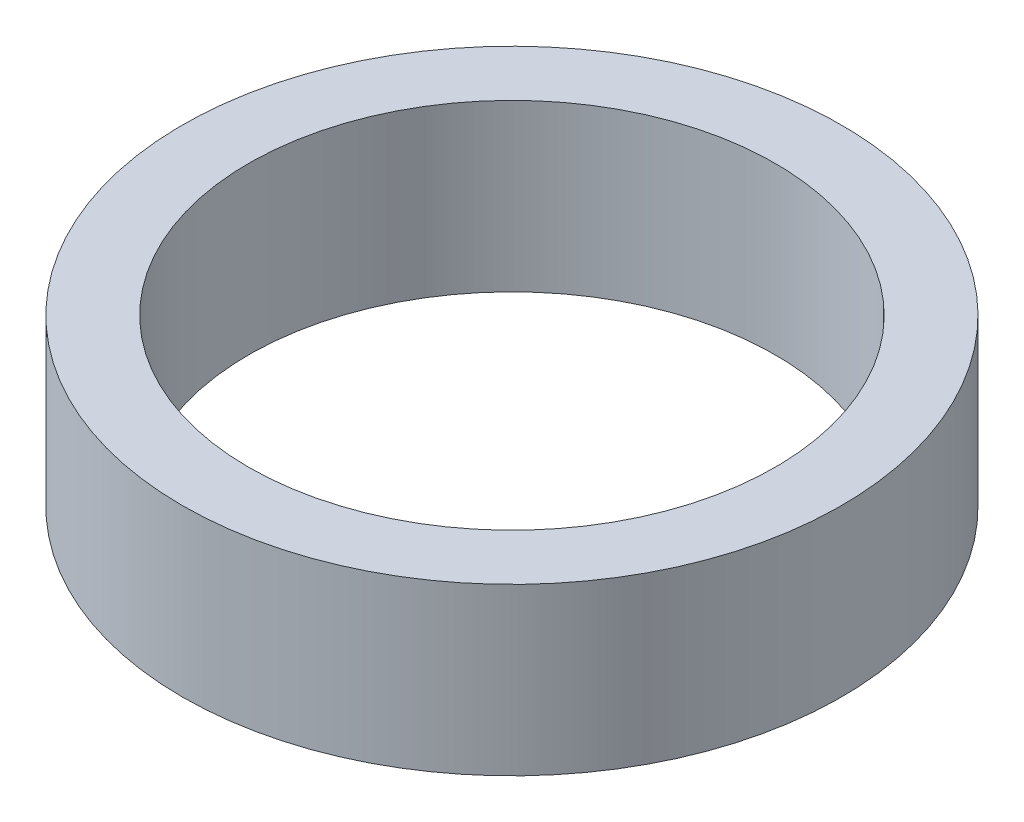
from build123d import *

# Parameters (mm, degrees)
SKETCH1_R           = 15.775
SKETCH1_R_2         = 12.6
BOSS_EXTRUDE1_DEPTH = 3.96875


with BuildPart() as part:
    # Sketch1 → Boss-Extrude1 (new body, symmetric)
    with BuildSketch(Plane(origin=(0, 0, 0), x_dir=(1, 0, 0), z_dir=(0, 1, 0))):
        Circle(SKETCH1_R)
        Circle(SKETCH1_R_2, mode=Mode.SUBTRACT)
    extrude(amount=BOSS_EXTRUDE1_DEPTH, both=True)


solid = part.part
